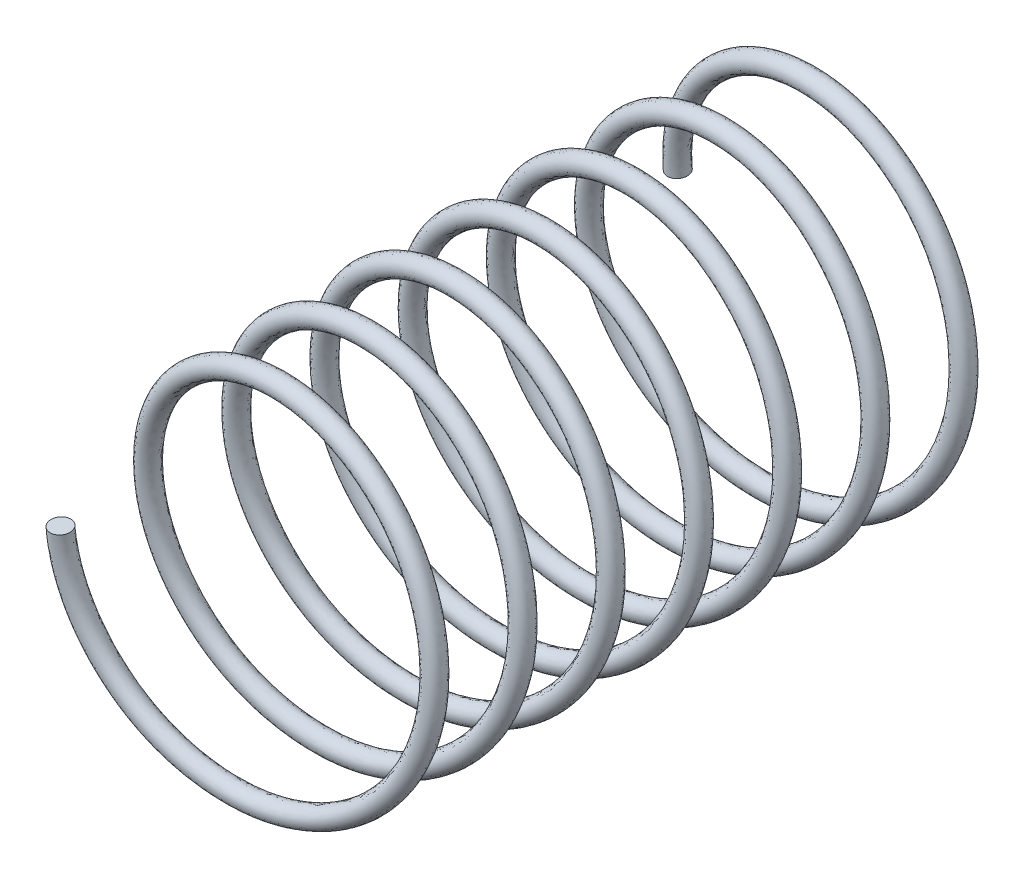
from build123d import *

# Parameters (mm, degrees)
SWEEP1_PITCH       = 1.071428571
SWEEP1_HEIGHT      = 7.5
SWEEP1_RADIUS      = 2
SWEEP1_START_ANGLE = -180
SWEEP1_PROFILE_R   = 0.125


with BuildPart() as part:
    # Sweep1: sweep along a helix
    with BuildLine() as sweep1_path:
        add(Helix(SWEEP1_PITCH, SWEEP1_HEIGHT, SWEEP1_RADIUS, center=(0, 0, 0), direction=(0, 0, 1), lefthand=True, mode=Mode.PRIVATE).rotate(Axis((0, 0, 0), (0, 0, 1)), SWEEP1_START_ANGLE))
    # Sweep1 profile (on start of the path) → Sweep1 (sweep)
    with BuildSketch(Plane(origin=(-2, 0, 0), x_dir=(0, -0.08495335, 0.99638493), z_dir=(0, 0.99638493, 0.08495335))):
        Circle(SWEEP1_PROFILE_R)
    sweep(path=sweep1_path.line, is_frenet=True)


solid = part.part
